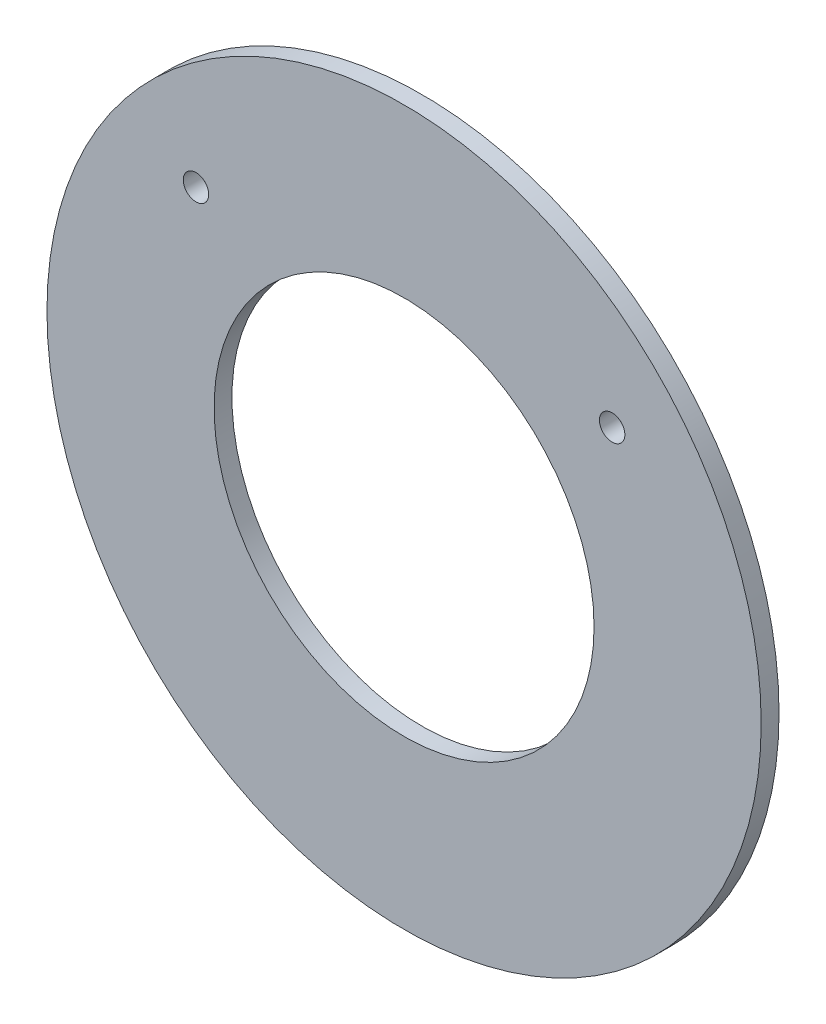
from build123d import *

# Parameters (mm, degrees)
SKETCH1_R           = 31.75
SKETCH1_R_2         = 16.891
BOSS_EXTRUDE1_DEPTH = 1.5875
SKETCH2_R           = 1.1303
CUT_EXTRUDE1_DEPTH  = 1.5875


with BuildPart() as part:
    # Sketch1 → Boss-Extrude1 (new body)
    with BuildSketch(Plane.XY):
        with Locations((25.5, 19.155)):
            Circle(SKETCH1_R)
        with Locations((25.5, 19.155)):
            Circle(SKETCH1_R_2, mode=Mode.SUBTRACT)
    extrude(amount=BOSS_EXTRUDE1_DEPTH)

    # Sketch2 → Cut-Extrude1 (cut)
    with BuildSketch(Plane(origin=(0, 0, 0), x_dir=(-1, 0, 0), z_dir=(0, 0, -1))):
        with Locations((-7, 35.31)):
            Circle(SKETCH2_R)
        with Locations((-44, 35.31)):
            Circle(SKETCH2_R)
    extrude(amount=-CUT_EXTRUDE1_DEPTH, mode=Mode.SUBTRACT)


solid = part.part
